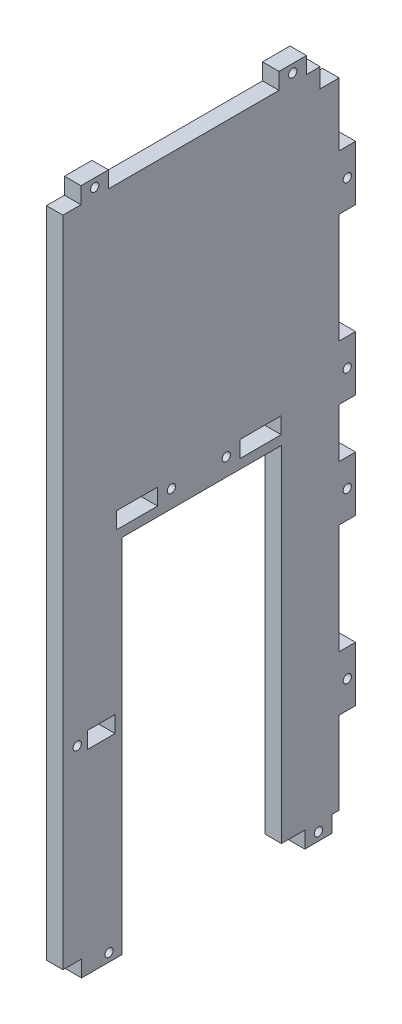
from build123d import *

# Parameters (mm, degrees)
ESQUISSE1_W             = 100.58
ESQUISSE1_H             = 238
ESQUISSE1_W_2           = 10
ESQUISSE1_H_2           = 6
ESQUISSE1_W_3           = 15
BOSS_EXTRU_1_DEPTH      = 6
ESQUISSE3_W             = 20
ESQUISSE3_H             = 6
ESQUISSE3_W_2           = 10
ESQUISSE3_W_3           = 6
ESQUISSE3_H_2           = 20
BOSS_EXTRU_5_DEPTH      = 6
ESQUISSE6_W             = 58
ESQUISSE6_H             = 131.59
ENL_V_MAT_EXTRU_2_DEPTH = 6
ESQUISSE7_W             = 6.88
ESQUISSE7_H             = 7
ENL_V_MAT_EXTRU_3_DEPTH = 6
ESQUISSE8_R             = 1.5
ENL_V_MAT_EXTRU_4_DEPTH = 6


with BuildPart() as part:
    # Esquisse1 → Boss.-Extru.1 (new body)
    with BuildSketch(Plane(origin=(0, 0, 0), x_dir=(0, 0, -1), z_dir=(1, 0, 0))):
        Rectangle(ESQUISSE1_W, ESQUISSE1_H)
        with Locations((-36.29, -51)):
            Rectangle(ESQUISSE1_W_2, ESQUISSE1_H_2, mode=Mode.SUBTRACT)
        with Locations((-23.295, 13)):
            Rectangle(ESQUISSE1_W_3, ESQUISSE1_H_2, mode=Mode.SUBTRACT)
        with Locations((21.705, 13)):
            Rectangle(ESQUISSE1_W_3, ESQUISSE1_H_2, mode=Mode.SUBTRACT)
    extrude(amount=BOSS_EXTRU_1_DEPTH)

    # Esquisse3 → Boss.-Extru.5 (add)
    with BuildSketch(Plane(origin=(6, 0, 0), x_dir=(0, 0, -1), z_dir=(1, 0, 0))):
        with Locations((-33.5, -122)):
            Rectangle(ESQUISSE3_W, ESQUISSE3_H)
        with Locations((42.79, -122)):
            Rectangle(ESQUISSE3_W_2, ESQUISSE3_H)
        with Locations((53.29, 19)):
            Rectangle(ESQUISSE3_W_3, ESQUISSE3_H_2)
        with Locations((53.29, 79)):
            Rectangle(ESQUISSE3_W_3, ESQUISSE3_H_2)
        with Locations((53.29, -79)):
            Rectangle(ESQUISSE3_W_3, ESQUISSE3_H_2)
        with Locations((53.29, -19)):
            Rectangle(ESQUISSE3_W_3, ESQUISSE3_H_2)
        with Locations((33.41, 122)):
            Rectangle(ESQUISSE3_W_2, ESQUISSE3_H)
        with Locations((-38.71, 122)):
            Rectangle(ESQUISSE3_W_2, ESQUISSE3_H)
    extrude(amount=-BOSS_EXTRU_5_DEPTH)

    # Esquisse6 → Enlèv. mat.-Extru.2 (cut)
    with BuildSketch(Plane(origin=(6, 0, 0), x_dir=(0, 0, -1), z_dir=(1, 0, 0))):
        with Locations((0.29, -59.205)):
            Rectangle(ESQUISSE6_W, ESQUISSE6_H)
    extrude(amount=-ENL_V_MAT_EXTRU_2_DEPTH, mode=Mode.SUBTRACT)

    # Esquisse7 → Enlèv. mat.-Extru.3 (cut)
    with BuildSketch(Plane.ZY):
        with Locations((-46.85, 115.5)):
            Rectangle(ESQUISSE7_W, ESQUISSE7_H)
    extrude(amount=-ENL_V_MAT_EXTRU_3_DEPTH, mode=Mode.SUBTRACT)

    # Esquisse8 → Enlèv. mat.-Extru.4 (cut)
    with BuildSketch(Plane.ZY):
        with Locations((-9.205, 13)):
            Circle(ESQUISSE8_R)
        with Locations((10.795, 13)):
            Circle(ESQUISSE8_R)
        with Locations((45.08, -51)):
            Circle(ESQUISSE8_R)
        with Locations((38.71, 122)):
            Circle(ESQUISSE8_R)
        with Locations((-33.41, 122)):
            Circle(ESQUISSE8_R)
        with Locations((33.5, -122)):
            Circle(ESQUISSE8_R)
        with Locations((-53.29, 79)):
            Circle(ESQUISSE8_R)
        with Locations((-42.79, -122)):
            Circle(ESQUISSE8_R)
        with Locations((-53.29, 19)):
            Circle(ESQUISSE8_R)
        with Locations((-53.29, -79)):
            Circle(ESQUISSE8_R)
        with Locations((-53.29, -19)):
            Circle(ESQUISSE8_R)
    extrude(amount=-ENL_V_MAT_EXTRU_4_DEPTH, mode=Mode.SUBTRACT)


solid = part.part
